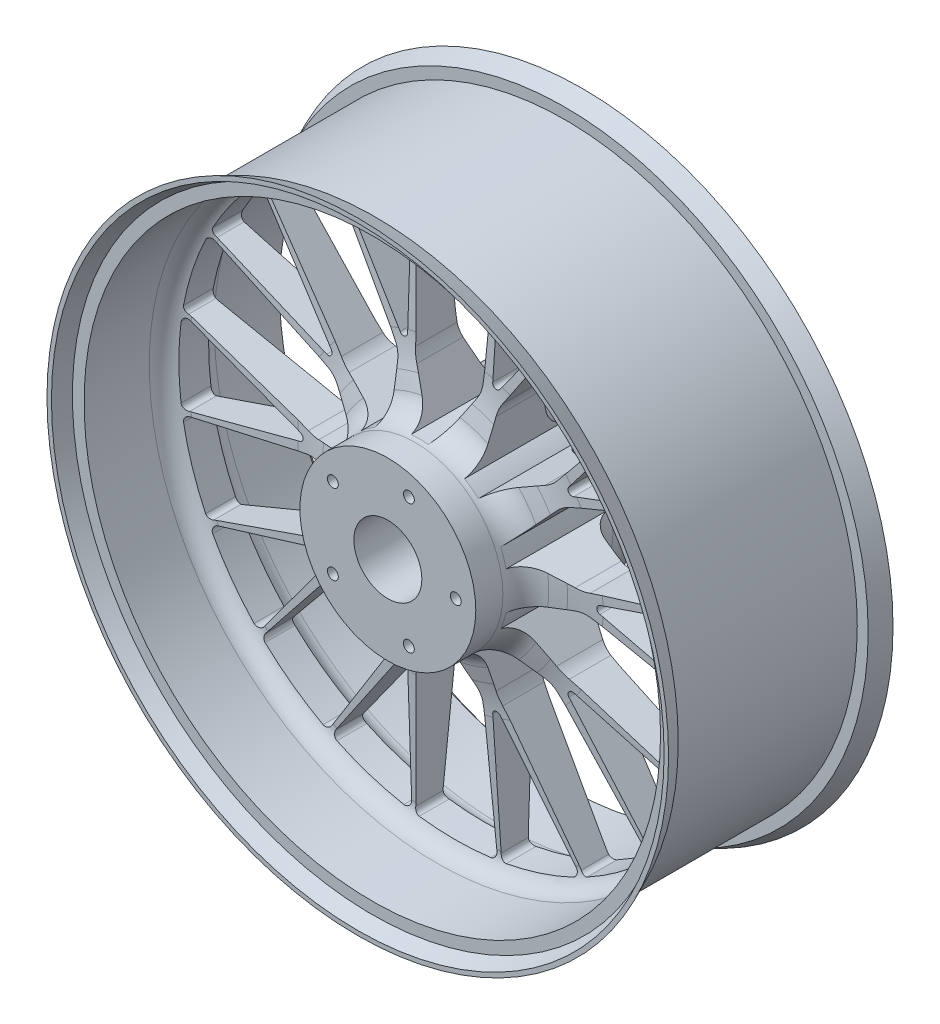
from build123d import *

# Parameters (mm, degrees)
SKETCH1_R             = 228.6
SKETCH1_R_2           = 25
SKETCH1_R_3           = 4
BOSS_EXTRUDE1_DEPTH   = 82.55
CROQUIS1_R            = 64.688179
CORTAR_EXTRUIR1_DEPTH = 22.125
CROQUIS2_R            = 64.688179
CORTAR_EXTRUIR2_DEPTH = 22.125


with BuildPart() as part:
    # Sketch1 → Boss-Extrude1 (new body, symmetric)
    with BuildSketch(Plane.XY):
        Circle(SKETCH1_R)
        Circle(SKETCH1_R_2, mode=Mode.SUBTRACT)
        with Locations((15.45085, 47.552826)):
            Circle(SKETCH1_R_3, mode=Mode.SUBTRACT)
        with Locations((50, 0)):
            Circle(SKETCH1_R_3, mode=Mode.SUBTRACT)
        with Locations((15.45085, -47.552826)):
            Circle(SKETCH1_R_3, mode=Mode.SUBTRACT)
        with Locations((-40.45085, -29.389263)):
            Circle(SKETCH1_R_3, mode=Mode.SUBTRACT)
        with Locations((-40.45085, 29.389263)):
            Circle(SKETCH1_R_3, mode=Mode.SUBTRACT)
        with BuildLine():
            Line((-29.808072, 197.311036), (-24.75602, 100.912126))
            ThreePointArc((-24.75602, 100.912126), (-23.959824, 96.278538), (-22.103937, 91.958845))
            Line((-22.103937, 91.958845), (-6.35921, 64.688179))
            ThreePointArc((-6.35921, 64.688179), (0, 65), (6.35921, 64.688179))
            Line((6.35921, 64.688179), (22.103937, 91.958845))
            ThreePointArc((22.103937, 91.958845), (23.959824, 96.278538), (24.75602, 100.912126))
            Line((24.75602, 100.912126), (29.808072, 197.311036))
            ThreePointArc((29.808072, 197.311036), (28.887709, 200.079593), (26.331899, 201.486652))
            ThreePointArc((26.331899, 201.486652), (0, 203.2), (-26.331899, 201.486652))
            ThreePointArc((-26.331899, 201.486652), (-28.887709, 200.079593), (-29.808072, 197.311036))
        make_face(mode=Mode.SUBTRACT)
        with BuildLine():
            Line((91.86128, 177.148727), (39.286619, 96.190848))
            ThreePointArc((39.286619, 96.190848), (37.2072, 91.974204), (36.169592, 87.388636))
            Line((36.169592, 87.388636), (32.878048, 56.071686))
            ThreePointArc((32.878048, 56.071686), (38.206041, 52.586105), (43.167467, 48.595986))
            Line((43.167467, 48.595986), (71.934513, 61.4039))
            ThreePointArc((71.934513, 61.4039), (75.975009, 63.807742), (79.3427, 67.088401))
            Line((79.3427, 67.088401), (140.091754, 142.107236))
            ThreePointArc((140.091754, 142.107236), (140.974482, 144.888022), (139.733836, 147.528624))
            ThreePointArc((139.733836, 147.528624), (119.437963, 164.392253), (97.127929, 178.483628))
            ThreePointArc((97.127929, 178.483628), (94.233187, 178.84756), (91.86128, 177.148727))
        make_face(mode=Mode.SUBTRACT)
        with BuildLine():
            Line((-31.301343, 105.619631), (-32.875918, 195.826934))
            ThreePointArc((-32.875918, 195.826934), (-34.34903, 198.858401), (-37.615776, 199.68799))
            ThreePointArc((-37.615776, 199.68799), (-62.772389, 193.261137), (-86.904095, 183.678846))
            ThreePointArc((-86.904095, 183.678846), (-89.059737, 181.088459), (-88.471019, 177.770281))
            Line((-88.471019, 177.770281), (-36.758343, 103.846544))
            ThreePointArc((-36.758343, 103.846544), (-35.2528, 102.722302), (-33.373835, 102.714104))
            ThreePointArc((-33.373835, 102.714104), (-31.85854, 103.825164), (-31.301343, 105.619631))
        make_face(mode=Mode.SUBTRACT)
        with BuildLine():
            Line((36.758343, 103.846544), (88.507008, 177.751297))
            ThreePointArc((88.507008, 177.751297), (89.097086, 181.069679), (86.941853, 183.660976))
            ThreePointArc((86.941853, 183.660976), (62.812117, 193.248229), (37.656827, 199.680253))
            ThreePointArc((37.656827, 199.680253), (34.390285, 198.851641), (32.916192, 195.821138))
            Line((32.916192, 195.821138), (31.301343, 105.619631))
            ThreePointArc((31.301343, 105.619631), (31.85854, 103.825164), (33.373835, 102.714104))
            ThreePointArc((33.373835, 102.714104), (35.2528, 102.722302), (36.758343, 103.846544))
        make_face(mode=Mode.SUBTRACT)
        with BuildLine():
            Line((178.442745, 89.321625), (88.323104, 54.727936))
            ThreePointArc((88.323104, 54.727936), (84.162338, 52.538851), (80.627566, 49.438939))
            Line((80.627566, 49.438939), (59.55701, 26.037715))
            ThreePointArc((59.55701, 26.037715), (61.818674, 20.086105), (63.487218, 13.941778))
            Line((63.487218, 13.941778), (94.288551, 7.394753))
            ThreePointArc((94.288551, 7.394753), (98.970324, 6.964558), (103.623165, 7.639188))
            Line((103.623165, 7.639188), (196.865147, 32.623302))
            ThreePointArc((196.865147, 32.623302), (199.213794, 34.354151), (199.762198, 37.219676))
            ThreePointArc((199.762198, 37.219676), (193.254684, 62.792253), (183.48819, 87.305924))
            ThreePointArc((183.48819, 87.305924), (181.360208, 89.301838), (178.442745, 89.321625))
        make_face(mode=Mode.SUBTRACT)
        with BuildLine():
            Line((90.777591, 62.407607), (176.083264, 91.780706))
            ThreePointArc((176.083264, 91.780706), (178.511144, 94.118494), (178.29065, 97.481712))
            ThreePointArc((178.29065, 97.481712), (164.404529, 119.421065), (147.834121, 139.41059))
            ThreePointArc((147.834121, 139.41059), (144.704387, 140.660254), (141.730536, 139.074977))
            Line((141.730536, 139.074977), (87.40498, 67.049608))
            ThreePointArc((87.40498, 67.049608), (86.801001, 65.270343), (87.373835, 63.480807))
            ThreePointArc((87.373835, 63.480807), (88.898769, 62.383012), (90.777591, 62.407607))
        make_face(mode=Mode.SUBTRACT)
        with BuildLine():
            Line((196.865147, -32.623302), (103.623165, -7.639188))
            ThreePointArc((103.623165, -7.639188), (98.970324, -6.964558), (94.288551, -7.394753))
            Line((94.288551, -7.394753), (63.487218, -13.941778))
            ThreePointArc((63.487218, -13.941778), (61.818674, -20.086105), (59.55701, -26.037715))
            Line((59.55701, -26.037715), (80.627566, -49.438939))
            ThreePointArc((80.627566, -49.438939), (84.162338, -52.538851), (88.323104, -54.727936))
            Line((88.323104, -54.727936), (178.442745, -89.321625))
            ThreePointArc((178.442745, -89.321625), (181.360208, -89.301838), (183.48819, -87.305924))
            ThreePointArc((183.48819, -87.305924), (193.254684, -62.792253), (199.762198, -37.219676))
            ThreePointArc((199.762198, -37.219676), (199.213794, -34.354151), (196.865147, -32.623302))
        make_face(mode=Mode.SUBTRACT)
        with BuildLine():
            Line((110.122885, -2.868914), (196.401699, -29.246995))
            ThreePointArc((196.401699, -29.246995), (199.740012, -28.782757), (201.538478, -25.932253))
            ThreePointArc((201.538478, -25.932253), (203.199999, -0.020887), (201.543805, 25.890821))
            ThreePointArc((201.543805, 25.890821), (199.746331, 28.741432), (196.408632, 29.206901))
            Line((196.408632, 29.206901), (110.122885, 2.868914))
            ThreePointArc((110.122885, 2.868914), (108.588429, 1.784468), (108, 0))
            ThreePointArc((108, 0), (108.588429, -1.784468), (110.122885, -2.868914))
        make_face(mode=Mode.SUBTRACT)
        with BuildLine():
            Line((140.091754, -142.107236), (79.3427, -67.088401))
            ThreePointArc((79.3427, -67.088401), (75.975009, -63.807742), (71.934513, -61.4039))
            Line((71.934513, -61.4039), (43.167467, -48.595986))
            ThreePointArc((43.167467, -48.595986), (38.206041, -52.586105), (32.878048, -56.071686))
            Line((32.878048, -56.071686), (36.169592, -87.388636))
            ThreePointArc((36.169592, -87.388636), (37.2072, -91.974204), (39.286619, -96.190848))
            Line((39.286619, -96.190848), (91.86128, -177.148727))
            ThreePointArc((91.86128, -177.148727), (94.233187, -178.84756), (97.127929, -178.483628))
            ThreePointArc((97.127929, -178.483628), (119.437963, -164.392253), (139.733836, -147.528624))
            ThreePointArc((139.733836, -147.528624), (140.974482, -144.888022), (140.091754, -142.107236))
        make_face(mode=Mode.SUBTRACT)
        with BuildLine():
            Line((87.40498, -67.049608), (141.70136, -139.103338))
            ThreePointArc((141.70136, -139.103338), (144.674984, -140.689972), (147.805458, -139.440979))
            ThreePointArc((147.805458, -139.440979), (164.379976, -119.45486), (178.270606, -97.518362))
            ThreePointArc((178.270606, -97.518362), (178.491966, -94.155641), (176.065307, -91.817218))
            Line((176.065307, -91.817218), (90.777591, -62.407607))
            ThreePointArc((90.777591, -62.407607), (88.898769, -62.383012), (87.373835, -63.480807))
            ThreePointArc((87.373835, -63.480807), (86.801001, -65.270343), (87.40498, -67.049608))
        make_face(mode=Mode.SUBTRACT)
        with BuildLine():
            Line((29.808072, -197.311036), (24.75602, -100.912126))
            ThreePointArc((24.75602, -100.912126), (23.959824, -96.278538), (22.103937, -91.958845))
            Line((22.103937, -91.958845), (6.35921, -64.688179))
            ThreePointArc((6.35921, -64.688179), (0, -65), (-6.35921, -64.688179))
            Line((-6.35921, -64.688179), (-22.103937, -91.958845))
            ThreePointArc((-22.103937, -91.958845), (-23.959824, -96.278538), (-24.75602, -100.912126))
            Line((-24.75602, -100.912126), (-29.808072, -197.311036))
            ThreePointArc((-29.808072, -197.311036), (-28.887709, -200.079593), (-26.331899, -201.486652))
            ThreePointArc((-26.331899, -201.486652), (0, -203.2), (26.331899, -201.486652))
            ThreePointArc((26.331899, -201.486652), (28.887709, -200.079593), (29.808072, -197.311036))
        make_face(mode=Mode.SUBTRACT)
        with BuildLine():
            Line((31.301343, -105.619631), (32.875918, -195.826934))
            ThreePointArc((32.875918, -195.826934), (34.34903, -198.858401), (37.615776, -199.68799))
            ThreePointArc((37.615776, -199.68799), (62.772389, -193.261137), (86.904095, -183.678846))
            ThreePointArc((86.904095, -183.678846), (89.059737, -181.088459), (88.471019, -177.770281))
            Line((88.471019, -177.770281), (36.758343, -103.846544))
            ThreePointArc((36.758343, -103.846544), (35.2528, -102.722302), (33.373835, -102.714104))
            ThreePointArc((33.373835, -102.714104), (31.85854, -103.825164), (31.301343, -105.619631))
        make_face(mode=Mode.SUBTRACT)
        with BuildLine():
            Line((-91.86128, -177.148727), (-39.286619, -96.190848))
            ThreePointArc((-39.286619, -96.190848), (-37.2072, -91.974204), (-36.169592, -87.388636))
            Line((-36.169592, -87.388636), (-32.878048, -56.071686))
            ThreePointArc((-32.878048, -56.071686), (-38.206041, -52.586105), (-43.167467, -48.595986))
            Line((-43.167467, -48.595986), (-71.934513, -61.4039))
            ThreePointArc((-71.934513, -61.4039), (-75.975009, -63.807742), (-79.3427, -67.088401))
            Line((-79.3427, -67.088401), (-140.091754, -142.107236))
            ThreePointArc((-140.091754, -142.107236), (-140.974482, -144.888022), (-139.733836, -147.528624))
            ThreePointArc((-139.733836, -147.528624), (-119.437963, -164.392253), (-97.127929, -178.483628))
            ThreePointArc((-97.127929, -178.483628), (-94.233187, -178.84756), (-91.86128, -177.148727))
        make_face(mode=Mode.SUBTRACT)
        with BuildLine():
            Line((-36.758343, -103.846544), (-88.507008, -177.751297))
            ThreePointArc((-88.507008, -177.751297), (-89.097086, -181.069679), (-86.941853, -183.660976))
            ThreePointArc((-86.941853, -183.660976), (-62.812117, -193.248229), (-37.656827, -199.680253))
            ThreePointArc((-37.656827, -199.680253), (-34.390285, -198.851641), (-32.916192, -195.821138))
            Line((-32.916192, -195.821138), (-31.301343, -105.619631))
            ThreePointArc((-31.301343, -105.619631), (-31.85854, -103.825164), (-33.373835, -102.714104))
            ThreePointArc((-33.373835, -102.714104), (-35.2528, -102.722302), (-36.758343, -103.846544))
        make_face(mode=Mode.SUBTRACT)
        with BuildLine():
            Line((-178.442745, -89.321625), (-88.323104, -54.727936))
            ThreePointArc((-88.323104, -54.727936), (-84.162338, -52.538851), (-80.627566, -49.438939))
            Line((-80.627566, -49.438939), (-59.55701, -26.037715))
            ThreePointArc((-59.55701, -26.037715), (-61.818674, -20.086105), (-63.487218, -13.941778))
            Line((-63.487218, -13.941778), (-94.288551, -7.394753))
            ThreePointArc((-94.288551, -7.394753), (-98.970324, -6.964558), (-103.623165, -7.639188))
            Line((-103.623165, -7.639188), (-196.865147, -32.623302))
            ThreePointArc((-196.865147, -32.623302), (-199.213794, -34.354151), (-199.762198, -37.219676))
            ThreePointArc((-199.762198, -37.219676), (-193.254684, -62.792253), (-183.48819, -87.305924))
            ThreePointArc((-183.48819, -87.305924), (-181.360208, -89.301838), (-178.442745, -89.321625))
        make_face(mode=Mode.SUBTRACT)
        with BuildLine():
            Line((-90.777591, -62.407607), (-176.083264, -91.780706))
            ThreePointArc((-176.083264, -91.780706), (-178.511144, -94.118494), (-178.29065, -97.481712))
            ThreePointArc((-178.29065, -97.481712), (-164.404529, -119.421065), (-147.834121, -139.41059))
            ThreePointArc((-147.834121, -139.41059), (-144.704387, -140.660254), (-141.730536, -139.074977))
            Line((-141.730536, -139.074977), (-87.40498, -67.049608))
            ThreePointArc((-87.40498, -67.049608), (-86.801001, -65.270343), (-87.373835, -63.480807))
            ThreePointArc((-87.373835, -63.480807), (-88.898769, -62.383012), (-90.777591, -62.407607))
        make_face(mode=Mode.SUBTRACT)
        with BuildLine():
            Line((-196.865147, 32.623302), (-103.623165, 7.639188))
            ThreePointArc((-103.623165, 7.639188), (-98.970324, 6.964558), (-94.288551, 7.394753))
            Line((-94.288551, 7.394753), (-63.487218, 13.941778))
            ThreePointArc((-63.487218, 13.941778), (-61.818674, 20.086105), (-59.55701, 26.037715))
            Line((-59.55701, 26.037715), (-80.627566, 49.438939))
            ThreePointArc((-80.627566, 49.438939), (-84.162338, 52.538851), (-88.323104, 54.727936))
            Line((-88.323104, 54.727936), (-178.442745, 89.321625))
            ThreePointArc((-178.442745, 89.321625), (-181.360208, 89.301838), (-183.48819, 87.305924))
            ThreePointArc((-183.48819, 87.305924), (-193.254684, 62.792253), (-199.762198, 37.219676))
            ThreePointArc((-199.762198, 37.219676), (-199.213794, 34.354151), (-196.865147, 32.623302))
        make_face(mode=Mode.SUBTRACT)
        with BuildLine():
            Line((-110.122885, 2.868914), (-196.401699, 29.246995))
            ThreePointArc((-196.401699, 29.246995), (-199.740012, 28.782757), (-201.538478, 25.932253))
            ThreePointArc((-201.538478, 25.932253), (-203.199999, 0.020887), (-201.543805, -25.890821))
            ThreePointArc((-201.543805, -25.890821), (-199.746331, -28.741432), (-196.408632, -29.206901))
            Line((-196.408632, -29.206901), (-110.122885, -2.868914))
            ThreePointArc((-110.122885, -2.868914), (-108.588429, -1.784468), (-108, 0))
            ThreePointArc((-108, 0), (-108.588429, 1.784468), (-110.122885, 2.868914))
        make_face(mode=Mode.SUBTRACT)
        with BuildLine():
            Line((-140.091754, 142.107236), (-79.3427, 67.088401))
            ThreePointArc((-79.3427, 67.088401), (-75.975009, 63.807742), (-71.934513, 61.4039))
            Line((-71.934513, 61.4039), (-43.167467, 48.595986))
            ThreePointArc((-43.167467, 48.595986), (-38.206041, 52.586105), (-32.878048, 56.071686))
            Line((-32.878048, 56.071686), (-36.169592, 87.388636))
            ThreePointArc((-36.169592, 87.388636), (-37.2072, 91.974204), (-39.286619, 96.190848))
            Line((-39.286619, 96.190848), (-91.86128, 177.148727))
            ThreePointArc((-91.86128, 177.148727), (-94.233187, 178.84756), (-97.127929, 178.483628))
            ThreePointArc((-97.127929, 178.483628), (-119.437963, 164.392253), (-139.733836, 147.528624))
            ThreePointArc((-139.733836, 147.528624), (-140.974482, 144.888022), (-140.091754, 142.107236))
        make_face(mode=Mode.SUBTRACT)
        with BuildLine():
            Line((-87.40498, 67.049608), (-141.70136, 139.103338))
            ThreePointArc((-141.70136, 139.103338), (-144.674984, 140.689972), (-147.805458, 139.440979))
            ThreePointArc((-147.805458, 139.440979), (-164.379976, 119.45486), (-178.270606, 97.518362))
            ThreePointArc((-178.270606, 97.518362), (-178.491966, 94.155641), (-176.065307, 91.817218))
            Line((-176.065307, 91.817218), (-90.777591, 62.407607))
            ThreePointArc((-90.777591, 62.407607), (-88.898769, 62.383012), (-87.373835, 63.480807))
            ThreePointArc((-87.373835, 63.480807), (-86.801001, 65.270343), (-87.40498, 67.049608))
        make_face(mode=Mode.SUBTRACT)
    extrude(amount=BOSS_EXTRUDE1_DEPTH, both=True)

    # Sketch2 → Cut-Revolve1 (revolve, cut)
    with BuildSketch(Plane(origin=(0, 0, 0), x_dir=(0, 0, -1), z_dir=(1, 0, 0))):
        with BuildLine():
            Line((-10, 197.311036), (-14.45576, 112.290072))
            ThreePointArc((-14.45576, 112.290072), (-15.690153, 101.018907), (-18.192544, 89.959932))
            Line((-18.192544, 89.959932), (-21.28495, 79.175431))
            ThreePointArc((-21.28495, 79.175431), (-28.473883, 68.715468), (-40.510184, 64.688179))
            Line((-40.510184, 64.688179), (-82.55, 64.688179))
            Line((-82.55, 64.688179), (-82.55, 225.321297))
            Line((-82.55, 225.321297), (-71.85, 220.603187))
            Line((-71.85, 220.603187), (-71.85, 212))
            Line((-71.85, 212), (-23.939306, 212))
            ThreePointArc((-23.939306, 212), (-13.814215, 207.649917), (-10, 197.311036))
        make_face()
        Polygon((-82.55, 228.6), (82.55, 228.6), (69.85, 223), (69.85, 215), (-69.85, 215), (-69.85, 223), align=None)
        with BuildLine():
            Line((71.85, 220.603187), (71.85, 212))
            Line((71.85, 212), (23.939306, 212))
            ThreePointArc((23.939306, 212), (13.814215, 207.649917), (10, 197.311036))
            Line((10, 197.311036), (14.45576, 112.290072))
            ThreePointArc((14.45576, 112.290072), (15.690153, 101.018907), (18.192544, 89.959932))
            Line((18.192544, 89.959932), (21.28495, 79.175431))
            ThreePointArc((21.28495, 79.175431), (28.473883, 68.715468), (40.510184, 64.688179))
            Line((40.510184, 64.688179), (82.55, 64.688179))
            Line((82.55, 64.688179), (82.55, 225.321297))
            Line((82.55, 225.321297), (71.85, 220.603187))
        make_face()
    revolve(axis=Axis((0, 0, 0), (0, 0, -1)), mode=Mode.SUBTRACT)

    # Croquis1 → Cortar-Extruir1 (cut)
    with BuildSketch(Plane.XY.offset(82.55)):
        Circle(CROQUIS1_R)
    extrude(amount=-CORTAR_EXTRUIR1_DEPTH, mode=Mode.SUBTRACT)

    # Croquis2 → Cortar-Extruir2 (cut)
    with BuildSketch(Plane(origin=(0, 0, -82.55), x_dir=(-1, 0, 0), z_dir=(0, 0, -1))):
        Circle(CROQUIS2_R)
    extrude(amount=-CORTAR_EXTRUIR2_DEPTH, mode=Mode.SUBTRACT)


solid = part.part
